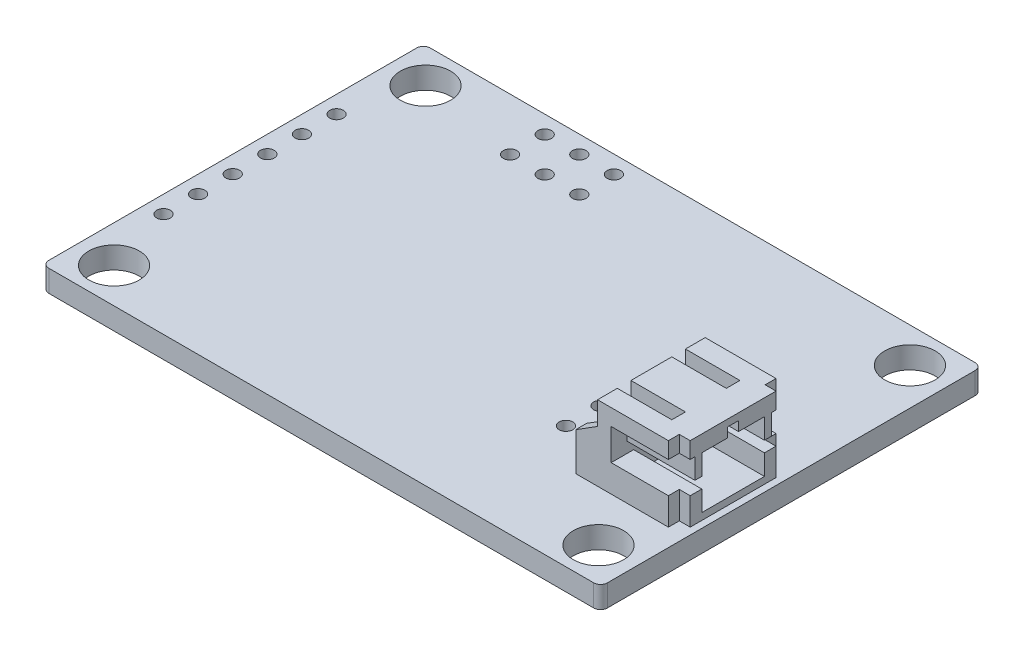
from build123d import *

# Parameters (mm, degrees)
SKETCH1_W           = 41
SKETCH1_H           = 28
SKETCH1_R           = 1.85
BOARD_DEPTH         = 1.6
SKETCH4_R           = 0.5
HOLES_DEPTH         = 2.6
FILLET1_R           = 0.5
SKETCH5_W           = 6
SKETCH5_H           = 3.95
BOSS_EXTRUDE2_DEPTH = 5.5
BOSS_EXTRUDE3_DEPTH = 0.8
CUT_EXTRUDE2_DEPTH  = 5
SKETCH7_W           = 4
SKETCH7_H           = 1
CUT_EXTRUDE3_DEPTH  = 1
SKETCH9_W           = 0.8
SKETCH9_H           = 0.8
CUT_EXTRUDE4_DEPTH  = 8.1


with BuildPart() as part:
    # Sketch1 → board (new body)
    with BuildSketch(Plane(origin=(0, 0, 0), x_dir=(1, 0, 0), z_dir=(0, 1, 0))):
        Rectangle(SKETCH1_W, SKETCH1_H)
        with Locations((-17.78, 11.43)):
            Circle(SKETCH1_R, mode=Mode.SUBTRACT)
        with Locations((-17.78, -11.43)):
            Circle(SKETCH1_R, mode=Mode.SUBTRACT)
        with Locations((17.78, -11.43)):
            Circle(SKETCH1_R, mode=Mode.SUBTRACT)
        with Locations((17.78, 11.43)):
            Circle(SKETCH1_R, mode=Mode.SUBTRACT)
    extrude(amount=BOARD_DEPTH)

    # Sketch4 → holes (cut, through all)
    with BuildSketch(Plane(origin=(0, 0, 0), x_dir=(1, 0, 0), z_dir=(0, 1, 0))):
        with Locations((-19.23, -6.35)):
            Circle(SKETCH4_R)
        with Locations((-19.23, -3.81)):
            Circle(SKETCH4_R)
        with Locations((-19.23, -1.27)):
            Circle(SKETCH4_R)
        with Locations((-19.23, 1.27)):
            Circle(SKETCH4_R)
        with Locations((-19.23, 3.81)):
            Circle(SKETCH4_R)
        with Locations((-19.23, 6.35)):
            Circle(SKETCH4_R)
        with Locations((-5.22, 10.16)):
            Circle(SKETCH4_R)
        with Locations((-7.76, 10.16)):
            Circle(SKETCH4_R)
        with Locations((-5.22, 12.7)):
            Circle(SKETCH4_R)
        with Locations((-7.76, 12.7)):
            Circle(SKETCH4_R)
        with Locations((-10.3, 12.7)):
            Circle(SKETCH4_R)
        with Locations((9, -5.04)):
            Circle(SKETCH4_R)
        with Locations((9, -2.5)):
            Circle(SKETCH4_R)
        with Locations((-10.3, 10.16)):
            Circle(SKETCH4_R)
    extrude(amount=HOLES_DEPTH, mode=Mode.SUBTRACT)

    # Fillet1
    fillet1_edges = [part.edges().sort_by_distance(p)[0] for p in [
        (20.5, 0.8, -14),
        (20.5, 0.8, 14),
        (-20.5, 0.8, 14),
        (-20.5, 0.8, -14),
    ]]
    fillet(fillet1_edges, radius=FILLET1_R)


with BuildPart() as body_2:
    # Sketch5 → Boss-Extrude2 (new body)
    with BuildSketch(Plane(origin=(0, 1.6, 0), x_dir=(1, 0, 0), z_dir=(0, 1, 0))):
        with Locations((17, -5.745)):
            Rectangle(SKETCH5_W, SKETCH5_H)
    extrude(amount=BOSS_EXTRUDE2_DEPTH)

    # Sketch8 → Boss-Extrude3 (add)
    with BuildSketch(Plane.XY.offset(7.72)):
        Polygon((12.4, 1.6), (12.4, 4.4), (14, 5.4), (14, 1.6), align=None)
    extrude(amount=-BOSS_EXTRUDE3_DEPTH)

    # Sketch6 → Cut-Extrude2 (cut)
    with BuildSketch(Plane(origin=(20, 0, 0), x_dir=(0, 0, -1), z_dir=(1, 0, 0))):
        Polygon((-6.07, 5.9), (-4.17, 5.9), (-4.17, 6.6), (-3.77, 6.6), (-3.77, 2.1), (-6.07, 2.1), (-6.07, 3.6), (-7.72, 3.6), (-7.72, 5.9), (-6.57, 5.9), (-6.57, 4.4), (-6.07, 4.4), align=None)
    extrude(amount=-CUT_EXTRUDE2_DEPTH, mode=Mode.SUBTRACT)

    # Sketch7 → Cut-Extrude3 (cut)
    with BuildSketch(Plane(origin=(0, 7.1, 0), x_dir=(1, 0, 0), z_dir=(0, 1, 0))):
        with Locations((16, -5.77)):
            Rectangle(SKETCH7_W, SKETCH7_H)
    extrude(amount=-CUT_EXTRUDE3_DEPTH, mode=Mode.SUBTRACT)

    # Sketch9 → Cut-Extrude4 (cut, through all)
    with BuildSketch(Plane(origin=(0, 7.1, 0), x_dir=(1, 0, 0), z_dir=(0, 1, 0))):
        with Locations((19.6, -7.32)):
            Rectangle(SKETCH9_W, SKETCH9_H)
    extrude(amount=-CUT_EXTRUDE4_DEPTH, mode=Mode.SUBTRACT)

    # Mirror1: body 2 across plane


with BuildPart() as body_2_1:
    add(body_2.part)
    add(body_2.part.mirror(Plane(origin=(14, 7.1, 3.77), x_dir=(1, 0, 0), z_dir=(0, 0, 1))))


solid = Compound([part.part, body_2_1.part])
